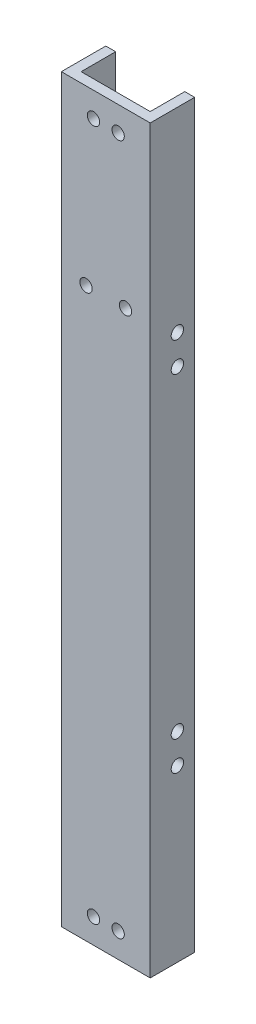
from build123d import *

# Parameters (mm, degrees)
BOSS_EXTRUDE1_DEPTH     = 150
SKETCH2_R               = 1.25
CUT_EXTRUDE1_DEPTH      = 10
SKETCH5_R               = 1.25
CUT_EXTRUDE2_DEPTH      = 1
CUT_EXTRUDE2_DEPTH_BACK = 19
SKETCH7_R               = 1.25
CUT_EXTRUDE3_DEPTH      = 2


with BuildPart() as part:
    # Sketch1 → Boss-Extrude1 (new body)
    with BuildSketch(Plane(origin=(0, 0, 0), x_dir=(1, 0, 0), z_dir=(0, 1, 0))):
        Polygon((-7, 4.5), (-7, -2.5), (7, -2.5), (7, 4.5), (9, 4.5), (9, -4.5), (-9, -4.5), (-9, 4.5), align=None)
    extrude(amount=BOSS_EXTRUDE1_DEPTH)

    # Sketch2 → Cut-Extrude1 (cut)
    with BuildSketch(Plane(origin=(0, 0, 2.5), x_dir=(-1, 0, 0), z_dir=(0, 0, -1))):
        with Locations((-2.5, 5)):
            Circle(SKETCH2_R)
        with Locations((2.5, 5)):
            Circle(SKETCH2_R)
        with Locations((2.5, 145)):
            Circle(SKETCH2_R)
        with Locations((-2.5, 145)):
            Circle(SKETCH2_R)
    extrude(amount=-CUT_EXTRUDE1_DEPTH, mode=Mode.SUBTRACT)

    # Sketch5 → Cut-Extrude2 (cut, two sides)
    with BuildSketch(Plane(origin=(9, 0, 0), x_dir=(0, 0, -1), z_dir=(1, 0, 0))) as cut_extrude2_sk:
        with Locations((1, 110.5)):
            Circle(SKETCH5_R)
        with Locations((1, 104.5)):
            Circle(SKETCH5_R)
        with Locations((1, 40.5)):
            Circle(SKETCH5_R)
        with Locations((1, 34.5)):
            Circle(SKETCH5_R)
    extrude(amount=CUT_EXTRUDE2_DEPTH, mode=Mode.SUBTRACT)
    extrude(cut_extrude2_sk.sketch, amount=-CUT_EXTRUDE2_DEPTH_BACK, mode=Mode.SUBTRACT)

    # Sketch7 → Cut-Extrude3 (cut)
    with BuildSketch(Plane.XY.offset(4.5)):
        with Locations((-4, 115)):
            Circle(SKETCH7_R)
        with Locations((4, 115)):
            Circle(SKETCH7_R)
    extrude(amount=-CUT_EXTRUDE3_DEPTH, mode=Mode.SUBTRACT)


solid = part.part
